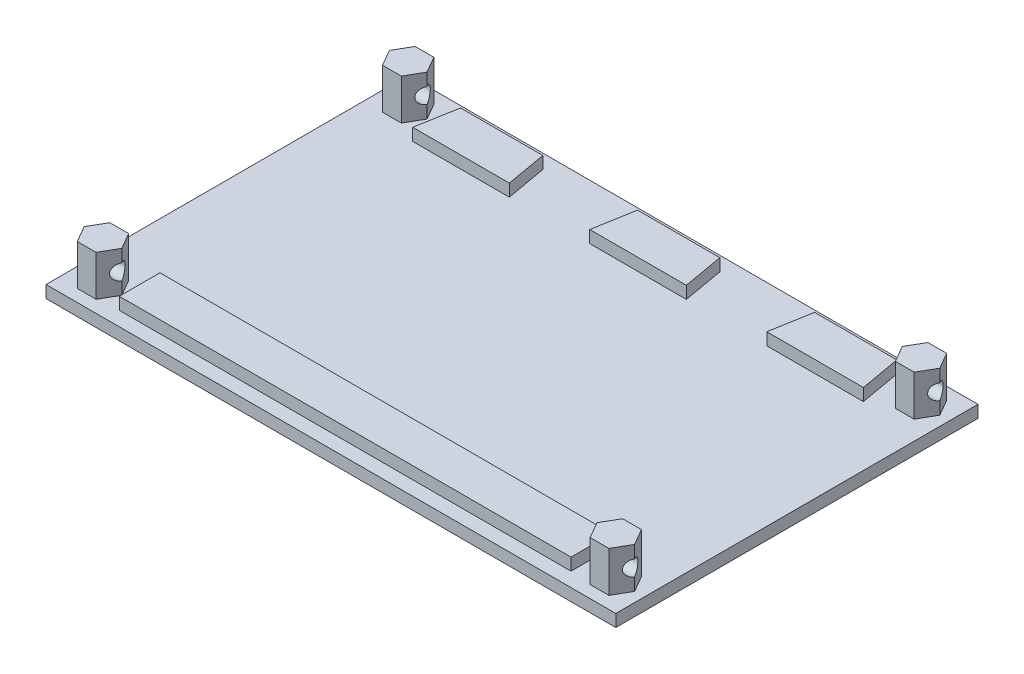
from build123d import *

# Parameters (mm, degrees)
SKETCH3_W           = 140
SKETCH3_H           = 89
BOSS_EXTRUDE1_DEPTH = 3
SKETCH2_W           = 111
SKETCH2_H           = 10
BOSS_EXTRUDE3_DEPTH = 3
BOSS_EXTRUDE4_DEPTH = 10
SKETCH4_R           = 1.9
CUT_EXTRUDE1_DEPTH  = 155.523815545


with BuildPart() as part:
    # Sketch3 → Boss-Extrude1 (new body)
    with BuildSketch(Plane(origin=(0, 0, 0), x_dir=(1, 0, 0), z_dir=(0, 1, 0))):
        with Locations((16.502784142, 20.134430227)):
            Rectangle(SKETCH3_W, SKETCH3_H)
    extrude(amount=-BOSS_EXTRUDE1_DEPTH)

    # Sketch2 → Boss-Extrude3 (add)
    with BuildSketch(Plane(origin=(0, 0, 0), x_dir=(1, 0, 0), z_dir=(0, 1, 0))):
        Polygon((-16.919207001, 61.134430227), (-37.138069254, 61.134430227), (-38.901339061, 51.134430227), (-15.155937194, 51.134430227), align=None)
        Polygon((4.598660939, 51.134430227), (28.344062806, 51.134430227), (26.580792999, 61.134430227), (6.361930746, 61.134430227), align=None)
        Polygon((48.098660939, 51.134430227), (71.844062806, 51.134430227), (70.080792999, 61.134430227), (49.861930746, 61.134430227), align=None)
        with Locations((16.502784142, -15.865569773)):
            Rectangle(SKETCH2_W, SKETCH2_H)
    extrude(amount=BOSS_EXTRUDE3_DEPTH)

    # Sketch2_4 → Boss-Extrude4 (add)
    with BuildSketch(Plane(origin=(0, 0, 0), x_dir=(1, 0, 0), z_dir=(0, 1, 0))):
        Polygon((-44.187814781, -13.365569773), (-48.806616934, -13.365569773), (-51.116018011, -17.365569773), (-48.806616934, -21.365569773), (-44.187814781, -21.365569773), (-41.878413704, -17.365569773), align=None)
        Polygon((-48.806616934, 53.634430227), (-44.187814781, 53.634430227), (-41.878413704, 57.634430227), (-44.187814781, 61.634430227), (-48.806616934, 61.634430227), (-51.116018011, 57.634430227), align=None)
        Polygon((74.883981989, 57.634430227), (77.193383066, 53.634430227), (81.812185219, 53.634430227), (84.121586296, 57.634430227), (81.812185219, 61.634430227), (77.193383066, 61.634430227), align=None)
        Polygon((81.812185219, -21.365569773), (84.121586296, -17.365569773), (81.812185219, -13.365569773), (77.193383066, -13.365569773), (74.883981989, -17.365569773), (77.193383066, -21.365569773), align=None)
    extrude(amount=BOSS_EXTRUDE4_DEPTH)

    # Sketch4 → Cut-Extrude1 (cut, through all)
    with BuildSketch(Plane.ZY.offset(53.497215858)):
        with Locations((-57.634430227, 5)):
            Circle(SKETCH4_R)
        with Locations((17.365569773, 5)):
            Circle(SKETCH4_R)
    extrude(amount=-CUT_EXTRUDE1_DEPTH, mode=Mode.SUBTRACT)


solid = part.part
